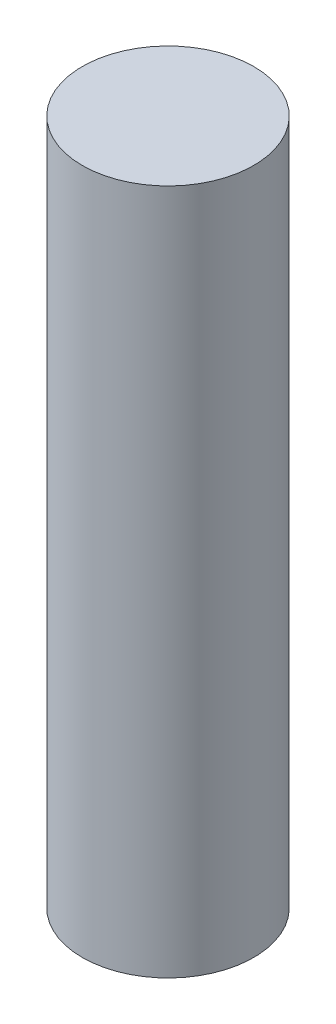
from build123d import *

# Parameters (mm, degrees)
ESBO_O1_R                = 10
RESSALTO_EXTRUS_O1_DEPTH = 80


with BuildPart() as part:
    # Esboço1 → Ressalto-extrusão1 (new body)
    with BuildSketch(Plane(origin=(0, 0, 0), x_dir=(1, 0, 0), z_dir=(0, 1, 0))):
        Circle(ESBO_O1_R)
    extrude(amount=RESSALTO_EXTRUS_O1_DEPTH)


solid = part.part
